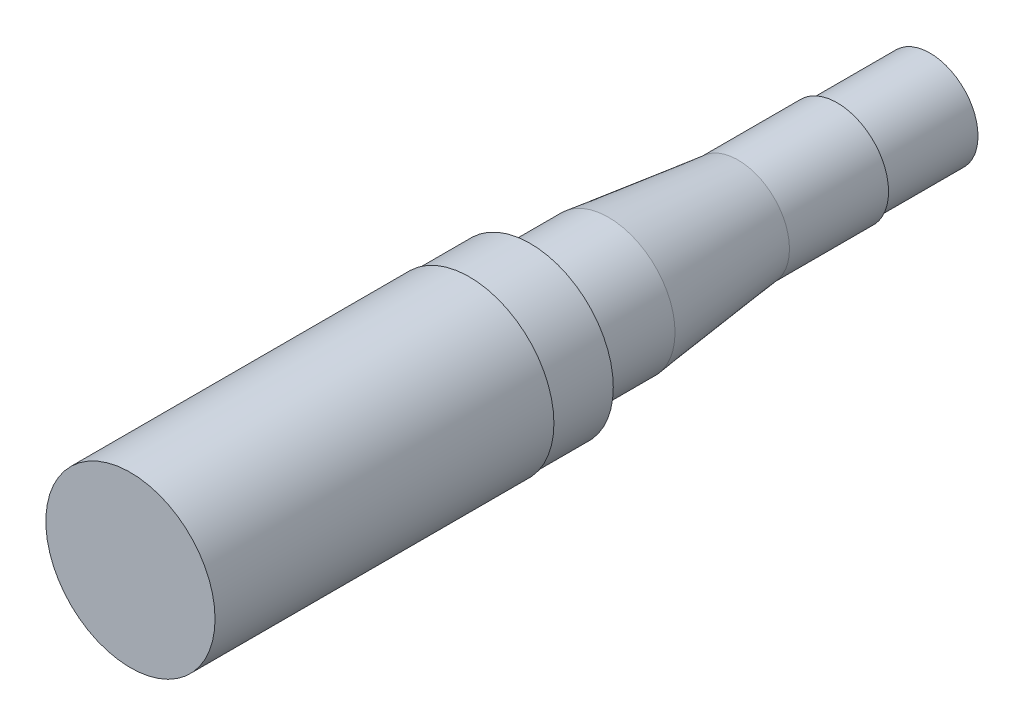
from build123d import *


with BuildPart() as part:
    # Sketch1 → Revolve1 (revolve)
    with BuildSketch(Plane(origin=(0, 0, 0), x_dir=(0, 0, -1), z_dir=(1, 0, 0)), mode=Mode.PRIVATE) as revolve1_sk:
        with BuildLine():
            Line((0, 0), (0, 22.225))
            Line((0, 22.225), (89.027, 22.225))
            Line((89.027, 22.225), (89.027, 21.8186))
            Line((89.027, 21.8186), (105.029, 21.8186))
            Line((105.029, 21.8186), (105.029, 19.3675))
            ThreePointArc((105.029, 19.3675), (105.586961582, 18.020461582), (106.934, 17.4625))
            Line((106.934, 17.4625), (125.603, 17.4625))
            Line((125.603, 17.4625), (159.639, 13.4874))
            Line((159.639, 13.4874), (185.674, 13.4874))
            Line((185.674, 13.4874), (185.674, 13.2334))
            ThreePointArc((185.674, 13.2334), (185.859987194, 12.784387194), (186.309, 12.5984))
            Line((186.309, 12.5984), (188.214, 12.5984))
            Line((188.214, 12.5984), (210.058, 12.5984))
            Line((210.058, 12.5984), (210.058, 0))
            Line((210.058, 0), (0, 0))
        make_face()
    revolve(revolve1_sk.sketch.rotate(Axis((0, 0, 0), (0, 0, -1)), 90), axis=Axis((0, 0, 0), (0, 0, -1)))


solid = part.part
